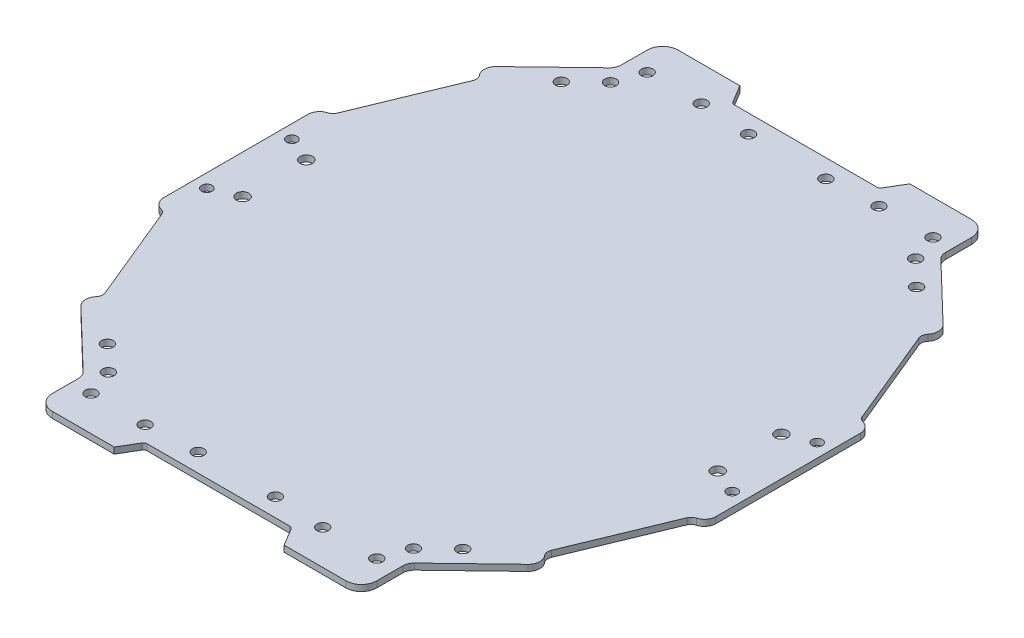
from build123d import *

# Parameters (mm, degrees)
SKETCH1_R        = 1.5
SKETCH1_R_2      = 1.35
SKETCH1_R_3      = 1.6
EXTRUSION1_DEPTH = 1.6
FILLET1_R        = 1
FILLET2_R        = 4
FILLET3_R        = 3
FILLET4_R        = 3
FILLET5_R        = 2
FILLET6_R        = 2
FILLET7_R        = 3
FILLET8_R        = 3
FILLET9_R        = 2
FILLET10_R       = 2
FILLET11_R       = 3


with BuildPart() as part:
    # Sketch1 → Extrusion1 (new body)
    with BuildSketch(Plane(origin=(0, 0, 0), x_dir=(-1, 0, 0), z_dir=(0, 1, 0))):
        Polygon((78.775158519, 259.059874387), (59.775158519, 259.059874387), (56.775158519, 264.05987395), (36.775158519, 264.05987395), (36.775158519, 252.05987395), (18.755330752, 234.731117294), (21.527931817, 231.847944851), (10.275158581, 204.559863083), (7.275158519, 204.559863083), (7.275158519, 183.059873956), (7.275158519, 161.559884829), (10.275158581, 161.559884829), (21.527931817, 134.27180306), (18.755330752, 131.388630617), (36.775158519, 114.059873961), (36.775158519, 102.059873961), (56.775158519, 102.059873961), (59.775158519, 107.059873524), (78.775158519, 107.059873524), (97.775158519, 107.059873524), (100.775158519, 102.059873961), (120.775158519, 102.059873961), (120.775158519, 114.059873961), (138.794986286, 131.388630617), (136.022385221, 134.27180306), (147.275158457, 161.559884829), (150.275158519, 161.559884829), (150.275158519, 183.059873956), (150.275158519, 204.559863083), (147.275158457, 204.559863083), (136.022385221, 231.847944851), (138.794986286, 234.731117294), (120.775158519, 252.05987395), (120.775158519, 264.05987395), (100.775158519, 264.05987395), (97.775158519, 259.059874387), align=None)
        with Locations((41.775158457, 111.059884829)):
            Circle(SKETCH1_R, mode=Mode.SUBTRACT)
        with Locations((39.275158457, 118.059884829)):
            Circle(SKETCH1_R, mode=Mode.SUBTRACT)
        with Locations((32.775158457, 124.309884829)):
            Circle(SKETCH1_R, mode=Mode.SUBTRACT)
        with Locations((10.775158457, 172.059872631)):
            Circle(SKETCH1_R_2, mode=Mode.SUBTRACT)
        with Locations((17.275158457, 174.809872631)):
            Circle(SKETCH1_R_3, mode=Mode.SUBTRACT)
        with Locations((55.775158457, 111.059872631)):
            Circle(SKETCH1_R, mode=Mode.SUBTRACT)
        with Locations((68.775158457, 111.809884829)):
            Circle(SKETCH1_R, mode=Mode.SUBTRACT)
        with Locations((88.775158581, 111.809884829)):
            Circle(SKETCH1_R, mode=Mode.SUBTRACT)
        with Locations((101.775158581, 111.059872631)):
            Circle(SKETCH1_R, mode=Mode.SUBTRACT)
        with Locations((115.775158581, 111.059884829)):
            Circle(SKETCH1_R, mode=Mode.SUBTRACT)
        with Locations((118.275158581, 118.059884829)):
            Circle(SKETCH1_R, mode=Mode.SUBTRACT)
        with Locations((124.775158581, 124.309884829)):
            Circle(SKETCH1_R, mode=Mode.SUBTRACT)
        with Locations((146.775158581, 172.059872631)):
            Circle(SKETCH1_R_2, mode=Mode.SUBTRACT)
        with Locations((140.275158581, 174.809872631)):
            Circle(SKETCH1_R_3, mode=Mode.SUBTRACT)
        with Locations((17.275158457, 191.30987528)):
            Circle(SKETCH1_R_3, mode=Mode.SUBTRACT)
        with Locations((10.775158457, 194.05987528)):
            Circle(SKETCH1_R_2, mode=Mode.SUBTRACT)
        with Locations((32.775158457, 241.809863083)):
            Circle(SKETCH1_R, mode=Mode.SUBTRACT)
        with Locations((39.275158457, 248.059863083)):
            Circle(SKETCH1_R, mode=Mode.SUBTRACT)
        with Locations((41.775158457, 255.059863083)):
            Circle(SKETCH1_R, mode=Mode.SUBTRACT)
        with Locations((140.275158581, 191.30987528)):
            Circle(SKETCH1_R_3, mode=Mode.SUBTRACT)
        with Locations((146.775158581, 194.05987528)):
            Circle(SKETCH1_R_2, mode=Mode.SUBTRACT)
        with Locations((55.775158457, 255.05987528)):
            Circle(SKETCH1_R, mode=Mode.SUBTRACT)
        with Locations((68.775158457, 254.309863083)):
            Circle(SKETCH1_R, mode=Mode.SUBTRACT)
        with Locations((88.775158581, 254.309863083)):
            Circle(SKETCH1_R, mode=Mode.SUBTRACT)
        with Locations((124.775158581, 241.809863083)):
            Circle(SKETCH1_R, mode=Mode.SUBTRACT)
        with Locations((118.275158581, 248.059863083)):
            Circle(SKETCH1_R, mode=Mode.SUBTRACT)
        with Locations((101.775158581, 255.05987528)):
            Circle(SKETCH1_R, mode=Mode.SUBTRACT)
        with Locations((115.775158581, 255.059863083)):
            Circle(SKETCH1_R, mode=Mode.SUBTRACT)
    extrude(amount=EXTRUSION1_DEPTH)

    # Fillet1
    fillet1_edges = [part.edges().sort_by_distance(p)[0] for p in [
        (-97.775158519, 0.8, 259.059874387),
        (-97.775158519, 0.8, 107.059873524),
        (-59.775158519, 0.8, 107.059873524),
        (-59.775158519, 0.8, 259.059874387),
    ]]
    fillet(fillet1_edges, radius=FILLET1_R)

    # Fillet2
    fillet2_edges = [part.edges().sort_by_distance(p)[0] for p in [
        (-120.775158519, 0.8, 264.05987395),
        (-120.775158519, 0.8, 102.059873961),
        (-36.775158519, 0.8, 102.059873961),
        (-36.775158519, 0.8, 264.05987395),
    ]]
    fillet(fillet2_edges, radius=FILLET2_R)

    # Fillet3
    fillet3_edges = [part.edges().sort_by_distance(p)[0] for p in [
        (-120.775158519, 0.8, 252.05987395),
        (-120.775158519, 0.8, 114.059873961),
        (-36.775158519, 0.8, 114.059873961),
        (-36.775158519, 0.8, 252.05987395),
    ]]
    fillet(fillet3_edges, radius=FILLET3_R)

    # Fillet4
    fillet4_edges = [part.edges().sort_by_distance(p)[0] for p in [
        (-138.794986286, 0.8, 234.731117294),
    ]]
    fillet(fillet4_edges, radius=FILLET4_R)

    # Fillet5
    fillet5_edges = [part.edges().sort_by_distance(p)[0] for p in [
        (-136.022385221, 0.8, 231.847944851),
    ]]
    fillet(fillet5_edges, radius=FILLET5_R)

    # Fillet6
    fillet6_edges = [part.edges().sort_by_distance(p)[0] for p in [
        (-21.527931817, 0.8, 231.847944851),
    ]]
    fillet(fillet6_edges, radius=FILLET6_R)

    # Fillet7
    fillet7_edges = [part.edges().sort_by_distance(p)[0] for p in [
        (-18.755330752, 0.8, 234.731117294),
    ]]
    fillet(fillet7_edges, radius=FILLET7_R)

    # Fillet8
    fillet8_edges = [part.edges().sort_by_distance(p)[0] for p in [
        (-138.794986286, 0.8, 131.388630617),
        (-18.755330752, 0.8, 131.388630617),
    ]]
    fillet(fillet8_edges, radius=FILLET8_R)

    # Fillet9
    fillet9_edges = [part.edges().sort_by_distance(p)[0] for p in [
        (-21.527931817, 0.8, 134.27180306),
        (-136.022385221, 0.8, 134.27180306),
    ]]
    fillet(fillet9_edges, radius=FILLET9_R)

    # Fillet10
    fillet10_edges = [part.edges().sort_by_distance(p)[0] for p in [
        (-147.275158457, 0.8, 204.559863083),
        (-147.275158457, 0.8, 161.559884829),
        (-10.275158581, 0.8, 161.559884829),
        (-10.275158581, 0.8, 204.559863083),
    ]]
    fillet(fillet10_edges, radius=FILLET10_R)

    # Fillet11
    fillet11_edges = [part.edges().sort_by_distance(p)[0] for p in [
        (-150.275158519, 0.8, 161.559884829),
        (-150.275158519, 0.8, 204.559863083),
        (-7.275158519, 0.8, 204.559863083),
        (-7.275158519, 0.8, 161.559884829),
    ]]
    fillet(fillet11_edges, radius=FILLET11_R)


solid = part.part
